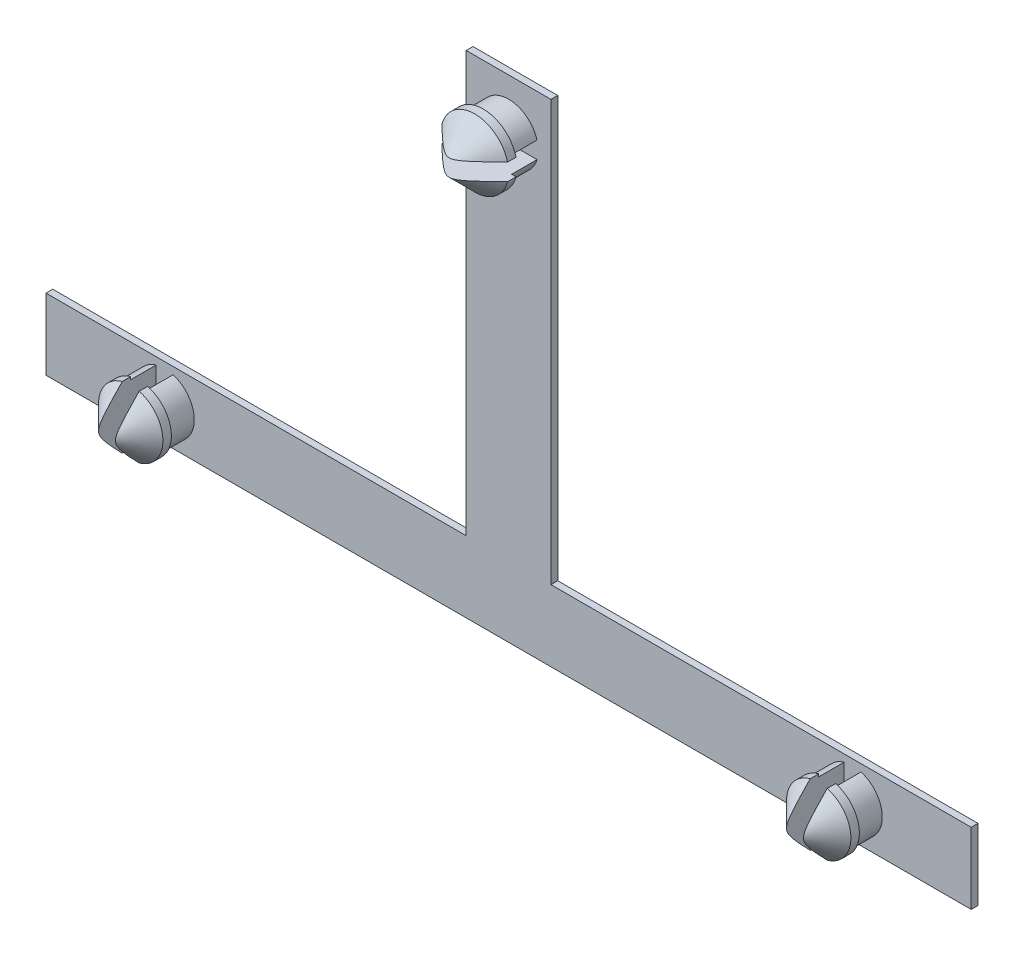
from build123d import *

# Parameters (mm, degrees)
SKICA2_W                 = 54.6
SKICA2_H                 = 4.2
P_IDAT_VYSUNUT_M2_DEPTH  = 0.4
SKICA3_R                 = 1.75
P_IDAT_VYSUNUT_M3_DEPTH  = 1.5
SKICA5_R                 = 1.9
P_IDAT_VYSUNUT_M5_DEPTH  = 2
ZKOSEN_2_SIZE            = 1.5
SKICA7_W                 = 1
SKICA7_H                 = 5
ODEBRAT_VYSUNUT_M1_DEPTH = 3.5
SKICA8_W                 = 5
SKICA8_H                 = 24.8
P_IDAT_VYSUNUT_M6_DEPTH  = 0.4
SKICA9_R                 = 1.75
P_IDAT_VYSUNUT_M7_DEPTH  = 1.5
SKICA10_R                = 2
P_IDAT_VYSUNUT_M8_DEPTH  = 2
ZKOSEN_3_SIZE            = 1.5
SKICA11_W                = 5
SKICA11_H                = 1
ODEBRAT_VYSUNUT_M2_DEPTH = 3.5


with BuildPart() as part:
    # Skica2 → Přidat vysunutím2 (new body)
    with BuildSketch(Plane.XY):
        Rectangle(SKICA2_W, SKICA2_H)
    extrude(amount=P_IDAT_VYSUNUT_M2_DEPTH)

    # Skica3 → Přidat vysunutím3 (add)
    with BuildSketch(Plane.XY.offset(0.4)):
        with Locations((-20.3, 0)):
            Circle(SKICA3_R)
        with Locations((20.3, 0)):
            Circle(SKICA3_R)
    extrude(amount=P_IDAT_VYSUNUT_M3_DEPTH)

    # Skica5 → Přidat vysunutím5 (add)
    with BuildSketch(Plane.XY.offset(1.9)):
        with Locations((-20.3, 0)):
            Circle(SKICA5_R)
        with Locations((20.3, 0)):
            Circle(SKICA5_R)
    extrude(amount=P_IDAT_VYSUNUT_M5_DEPTH)

    # Zkosení2
    zkosen_2_edges = [part.edges().sort_by_distance(p)[0] for p in [
        (-22.2, 0, 3.9),
        (18.4, 0, 3.9),
    ]]
    chamfer(zkosen_2_edges, length=ZKOSEN_2_SIZE)

    # Skica7 → Odebrat vysunutím1 (cut)
    with BuildSketch(Plane.XY.offset(3.9)):
        with Locations((-20.3, 0)):
            Rectangle(SKICA7_W, SKICA7_H)
        with Locations((20.3, 0)):
            Rectangle(SKICA7_W, SKICA7_H)
    extrude(amount=-ODEBRAT_VYSUNUT_M1_DEPTH, mode=Mode.SUBTRACT)

    # Skica8 → Přidat vysunutím6 (add)
    with BuildSketch(Plane(origin=(0, 0, 0), x_dir=(-1, 0, 0), z_dir=(0, 0, -1))):
        with Locations((0, 14.5)):
            Rectangle(SKICA8_W, SKICA8_H)
    extrude(amount=-P_IDAT_VYSUNUT_M6_DEPTH)

    # Skica9 → Přidat vysunutím7 (add)
    with BuildSketch(Plane.XY.offset(0.4)):
        with Locations((0, 23.910722543)):
            Circle(SKICA9_R)
    extrude(amount=P_IDAT_VYSUNUT_M7_DEPTH)

    # Skica10 → Přidat vysunutím8 (add)
    with BuildSketch(Plane.XY.offset(1.9)):
        with Locations((0, 23.910722543)):
            Circle(SKICA10_R)
    extrude(amount=P_IDAT_VYSUNUT_M8_DEPTH)

    # Zkosení3
    zkosen_3_edges = [part.edges().sort_by_distance(p)[0] for p in [
        (-2, 23.910722543, 3.9),
    ]]
    chamfer(zkosen_3_edges, length=ZKOSEN_3_SIZE)

    # Skica11 → Odebrat vysunutím2 (cut)
    with BuildSketch(Plane.XY.offset(3.9)):
        with Locations((0, 23.910722543)):
            Rectangle(SKICA11_W, SKICA11_H)
    extrude(amount=-ODEBRAT_VYSUNUT_M2_DEPTH, mode=Mode.SUBTRACT)


solid = part.part
